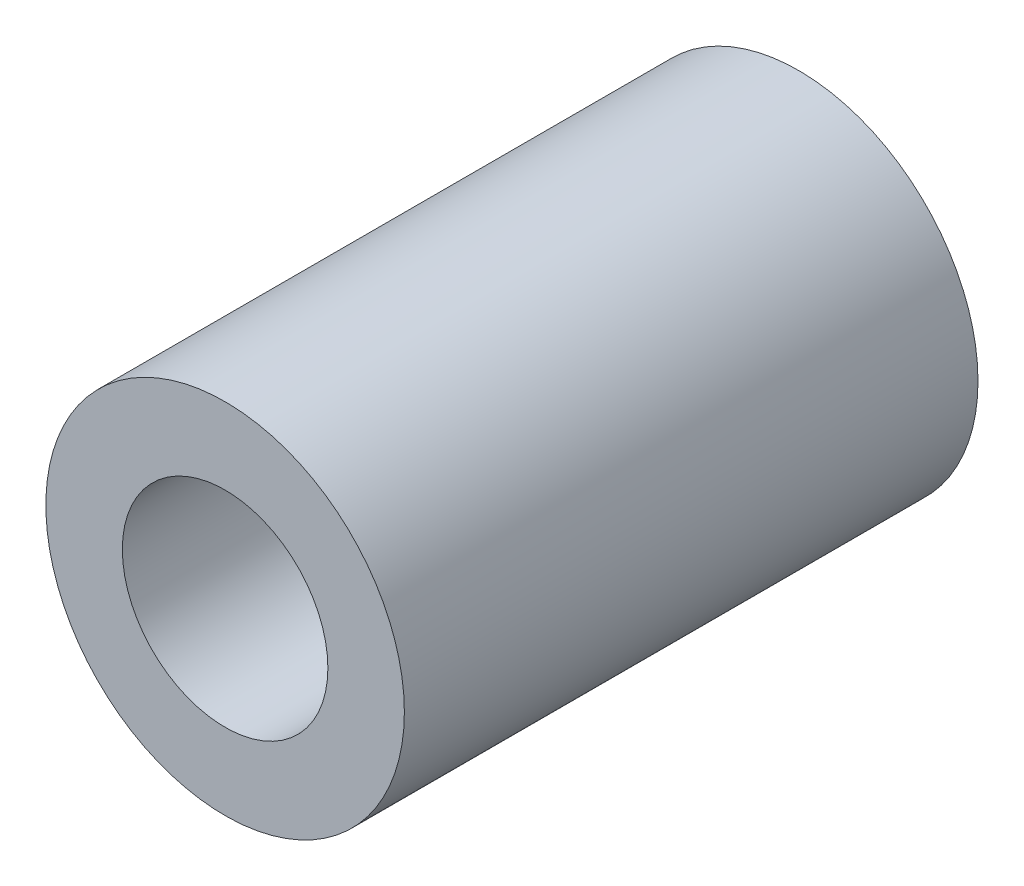
from build123d import *

# Parameters (mm, degrees)
CROQUIS1_R              = 7.5
CROQUIS1_R_2            = 4.3
SALIENTE_EXTRUIR1_DEPTH = 24


with BuildPart() as part:
    # Croquis1 → Saliente-Extruir1 (new body)
    with BuildSketch(Plane.XY):
        Circle(CROQUIS1_R)
        Circle(CROQUIS1_R_2, mode=Mode.SUBTRACT)
    extrude(amount=SALIENTE_EXTRUIR1_DEPTH)


solid = part.part
